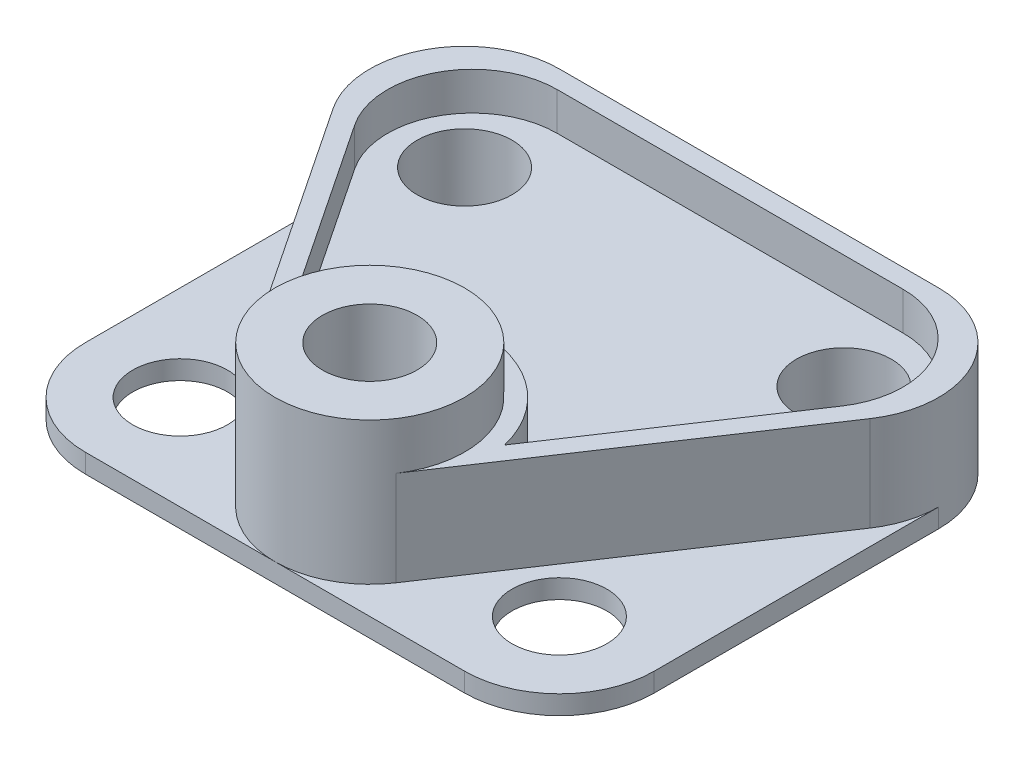
from build123d import *

# Parameters (mm, degrees)
SKETCH1_R           = 6.35
BOSS_EXTRUDE1_DEPTH = 2.54
BOSS_EXTRUDE2_DEPTH = 12.7
SKETCH2_3_R         = 6.35
BOSS_EXTRUDE3_DEPTH = 19.05
SKETCH2_5_R         = 6.35
BOSS_EXTRUDE4_DEPTH = 7.62
CUT_EXTRUDE1_START  = -7.62
SKETCH5_R           = 6.35
CUT_EXTRUDE1_DEPTH  = 7.62


with BuildPart() as part:
    # Sketch1 → Boss-Extrude1 (new body)
    with BuildSketch(Plane(origin=(0, 0, 0), x_dir=(1, 0, 0), z_dir=(0, 1, 0))):
        with BuildLine():
            Line((12.7, 0), (63.5, 0))
            ThreePointArc((63.5, 0), (72.480256121, 3.719743879), (76.2, 12.7))
            Line((76.2, 12.7), (76.2, 50.8))
            ThreePointArc((76.2, 50.8), (72.480256121, 59.780256121), (63.5, 63.5))
            Line((63.5, 63.5), (12.7, 63.5))
            ThreePointArc((12.7, 63.5), (3.719743879, 59.780256121), (0, 50.8))
            Line((0, 50.8), (0, 12.7))
            ThreePointArc((0, 12.7), (3.719743879, 3.719743879), (12.7, 0))
        make_face()
        with Locations((12.7, 12.7)):
            Circle(SKETCH1_R, mode=Mode.SUBTRACT)
        with Locations((63.5, 12.7)):
            Circle(SKETCH1_R, mode=Mode.SUBTRACT)
    extrude(amount=BOSS_EXTRUDE1_DEPTH)

    # Sketch2 → Boss-Extrude2 (add)
    with BuildSketch(Plane(origin=(0, 2.54, 0), x_dir=(1, 0, 0), z_dir=(0, 1, 0))):
        with BuildLine():
            Line((63.5, 63.5), (12.7, 63.5))
            ThreePointArc((12.7, 63.5), (3.719743879, 59.780256121), (0, 50.8))
            ThreePointArc((0, 50.8), (0.544931264, 47.119741312), (2.132961262, 43.755307508))
            Line((2.132961262, 43.755307508), (27.532961262, 5.655307508))
            ThreePointArc((27.532961262, 5.655307508), (34.419741312, 24.855068736), (50.8, 12.7))
            ThreePointArc((50.8, 12.7), (50.255068736, 9.019741312), (48.667038738, 5.655307508))
            Line((48.667038738, 5.655307508), (74.067038738, 43.755307508))
            ThreePointArc((74.067038738, 43.755307508), (75.655068736, 47.119741312), (76.2, 50.8))
            ThreePointArc((76.2, 50.8), (72.480256121, 59.780256121), (63.5, 63.5))
        make_face()
        with BuildLine():
            Line((23.553103988, 16.204143539), (5.488594295, 43.300908078))
            ThreePointArc((5.488594295, 43.300908078), (4.924935684, 54.961088143), (14.939453481, 60.96))
            Line((14.939453481, 60.96), (61.260546519, 60.96))
            ThreePointArc((61.260546519, 60.96), (71.275064316, 54.961088143), (70.711405705, 43.300908078))
            Line((70.711405705, 43.300908078), (52.646896012, 16.204143539))
            ThreePointArc((52.646896012, 16.204143539), (38.1, 27.662994537), (23.553103988, 16.204143539))
        make_face(mode=Mode.SUBTRACT)
    extrude(amount=BOSS_EXTRUDE2_DEPTH)

    # Sketch2_3 → Boss-Extrude3 (add)
    with BuildSketch(Plane(origin=(0, 2.54, 0), x_dir=(1, 0, 0), z_dir=(0, 1, 0))):
        with BuildLine():
            ThreePointArc((50.8, 12.7), (34.419741312, 24.855068736), (27.532961262, 5.655307508))
            ThreePointArc((27.532961262, 5.655307508), (38.1, 0), (48.667038738, 5.655307508))
            ThreePointArc((48.667038738, 5.655307508), (50.255068736, 9.019741312), (50.8, 12.7))
        make_face()
        with Locations((38.1, 12.7)):
            Circle(SKETCH2_3_R, mode=Mode.SUBTRACT)
    extrude(amount=BOSS_EXTRUDE3_DEPTH)

    # Sketch2_5 → Boss-Extrude4 (add)
    with BuildSketch(Plane(origin=(0, 2.54, 0), x_dir=(1, 0, 0), z_dir=(0, 1, 0))):
        with BuildLine():
            ThreePointArc((14.939453481, 60.96), (4.924935684, 54.961088143), (5.488594295, 43.300908078))
            Line((5.488594295, 43.300908078), (23.553103988, 16.204143539))
            ThreePointArc((23.553103988, 16.204143539), (38.1, 27.662994537), (52.646896012, 16.204143539))
            Line((52.646896012, 16.204143539), (70.711405705, 43.300908078))
            ThreePointArc((70.711405705, 43.300908078), (71.275064316, 54.961088143), (61.260546519, 60.96))
            Line((61.260546519, 60.96), (14.939453481, 60.96))
        make_face()
        with Locations((12.7, 50.8)):
            Circle(SKETCH2_5_R, mode=Mode.SUBTRACT)
        with Locations((63.5, 50.8)):
            Circle(SKETCH2_5_R, mode=Mode.SUBTRACT)
    extrude(amount=BOSS_EXTRUDE4_DEPTH)

    # Sketch5 → Cut-Extrude1 (cut)
    with BuildSketch(Plane(origin=(0, 2.54, 0), x_dir=(1, 0, 0), z_dir=(0, 1, 0)).offset(CUT_EXTRUDE1_START)):
        with Locations((12.7, 50.8)):
            Circle(SKETCH5_R)
        with Locations((63.5, 50.8)):
            Circle(SKETCH5_R)
        with Locations((38.1, 12.7)):
            Circle(SKETCH5_R)
    extrude(amount=CUT_EXTRUDE1_DEPTH, mode=Mode.SUBTRACT)


solid = part.part
